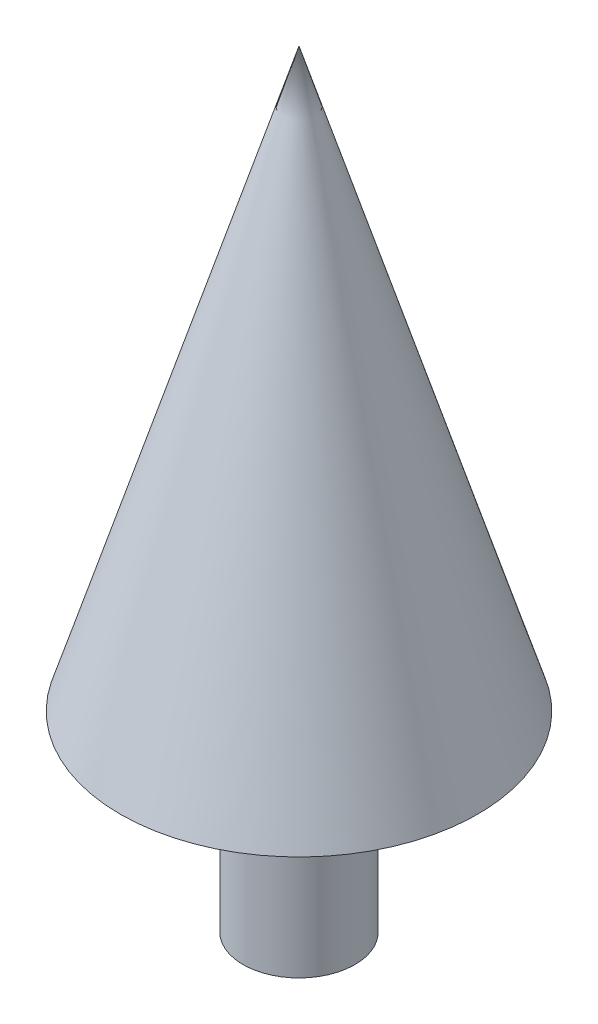
from build123d import *


with BuildPart() as part:
    # Sketch2 → Revolve1 (revolve)
    with BuildSketch(Plane.XY):
        Polygon((0, 0), (0, 450), (104.792134424, 112.325719713), (32.822074733, 112.325719713), (32.822074733, 0), align=None)
    revolve(axis=Axis((0, 0, 0), (0, 1, 0)))


solid = part.part
